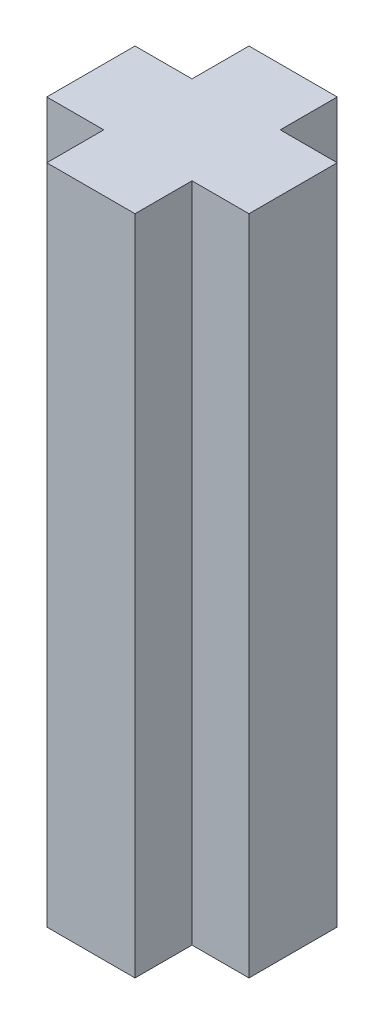
from build123d import *

# Parameters (mm, degrees)
BOSS_EXTRUDE1_DEPTH = 15


with BuildPart() as part:
    # Sketch1 → Boss-Extrude1 (new body)
    with BuildSketch(Plane(origin=(0, 0, 0), x_dir=(1, 0, 0), z_dir=(0, 1, 0))):
        Polygon((2.28066072, -0.952177928), (0.989372873, -0.952177928), (0.989372873, -2.243465776), (-1.010627127, -2.243465776), (-1.010627127, -0.952177928), (-2.301914975, -0.952177928), (-2.301914975, 1.047822072), (-1.010627127, 1.047822072), (-1.010627127, 2.339109919), (0.989372873, 2.339109919), (0.989372873, 1.047822072), (2.28066072, 1.047822072), align=None)
    extrude(amount=BOSS_EXTRUDE1_DEPTH)


solid = part.part
